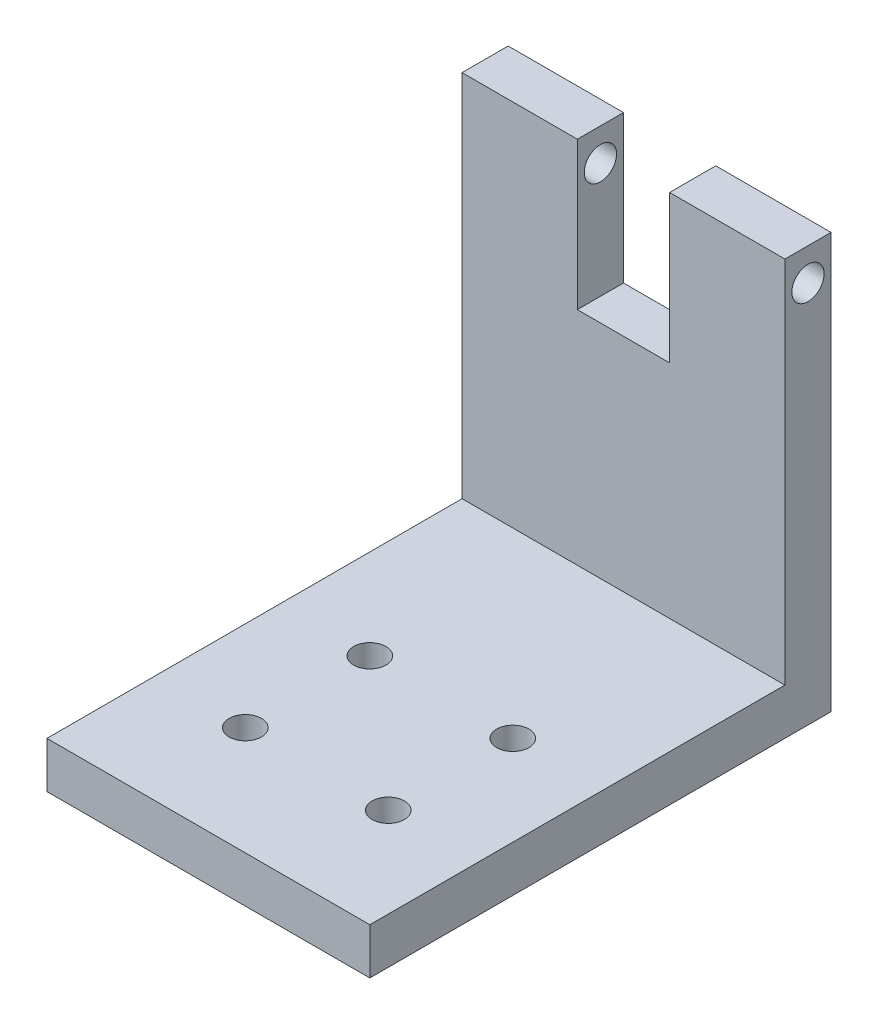
from build123d import *

# Parameters (mm, degrees)
SKETCH1_W           = 35
SKETCH1_H           = 50
BOSS_EXTRUDE1_DEPTH = 5
SKETCH2_R           = 1.75
CUT_EXTRUDE1_DEPTH  = 6
SKETCH3_W           = 12.5
SKETCH3_H           = 5
BOSS_EXTRUDE2_DEPTH = 40
SKETCH4_W           = 10
SKETCH4_H           = 5
BOSS_EXTRUDE3_DEPTH = 24
SKETCH5_R           = 1.75
CUT_EXTRUDE2_DEPTH  = 36


with BuildPart() as part:
    # Sketch1 → Boss-Extrude1 (new body)
    with BuildSketch(Plane(origin=(0, 0, 0), x_dir=(1, 0, 0), z_dir=(0, 1, 0))):
        with Locations((17.5, 25)):
            Rectangle(SKETCH1_W, SKETCH1_H)
    extrude(amount=BOSS_EXTRUDE1_DEPTH)

    # Sketch2 → Cut-Extrude1 (cut, through all)
    with BuildSketch(Plane(origin=(0, 5, 0), x_dir=(1, 0, 0), z_dir=(0, 1, 0))):
        with Locations((9.75, 11.75)):
            Circle(SKETCH2_R)
        with Locations((9.75, 25.25)):
            Circle(SKETCH2_R)
        with Locations((25.25, 11.75)):
            Circle(SKETCH2_R)
        with Locations((25.25, 25.25)):
            Circle(SKETCH2_R)
    extrude(amount=-CUT_EXTRUDE1_DEPTH, mode=Mode.SUBTRACT)

    # Sketch3 → Boss-Extrude2 (add)
    with BuildSketch(Plane(origin=(0, 5, 0), x_dir=(1, 0, 0), z_dir=(0, 1, 0))):
        with Locations((6.25, 47.5)):
            Rectangle(SKETCH3_W, SKETCH3_H)
        with Locations((28.75, 47.5)):
            Rectangle(SKETCH3_W, SKETCH3_H)
    extrude(amount=BOSS_EXTRUDE2_DEPTH)

    # Sketch4 → Boss-Extrude3 (add)
    with BuildSketch(Plane(origin=(0, 5, 0), x_dir=(1, 0, 0), z_dir=(0, 1, 0))):
        with Locations((17.5, 47.5)):
            Rectangle(SKETCH4_W, SKETCH4_H)
    extrude(amount=BOSS_EXTRUDE3_DEPTH)

    # Sketch5 → Cut-Extrude2 (cut, through all)
    with BuildSketch(Plane.ZY):
        with Locations((-47.5, 41.5)):
            Circle(SKETCH5_R)
    extrude(amount=-CUT_EXTRUDE2_DEPTH, mode=Mode.SUBTRACT)


solid = part.part
